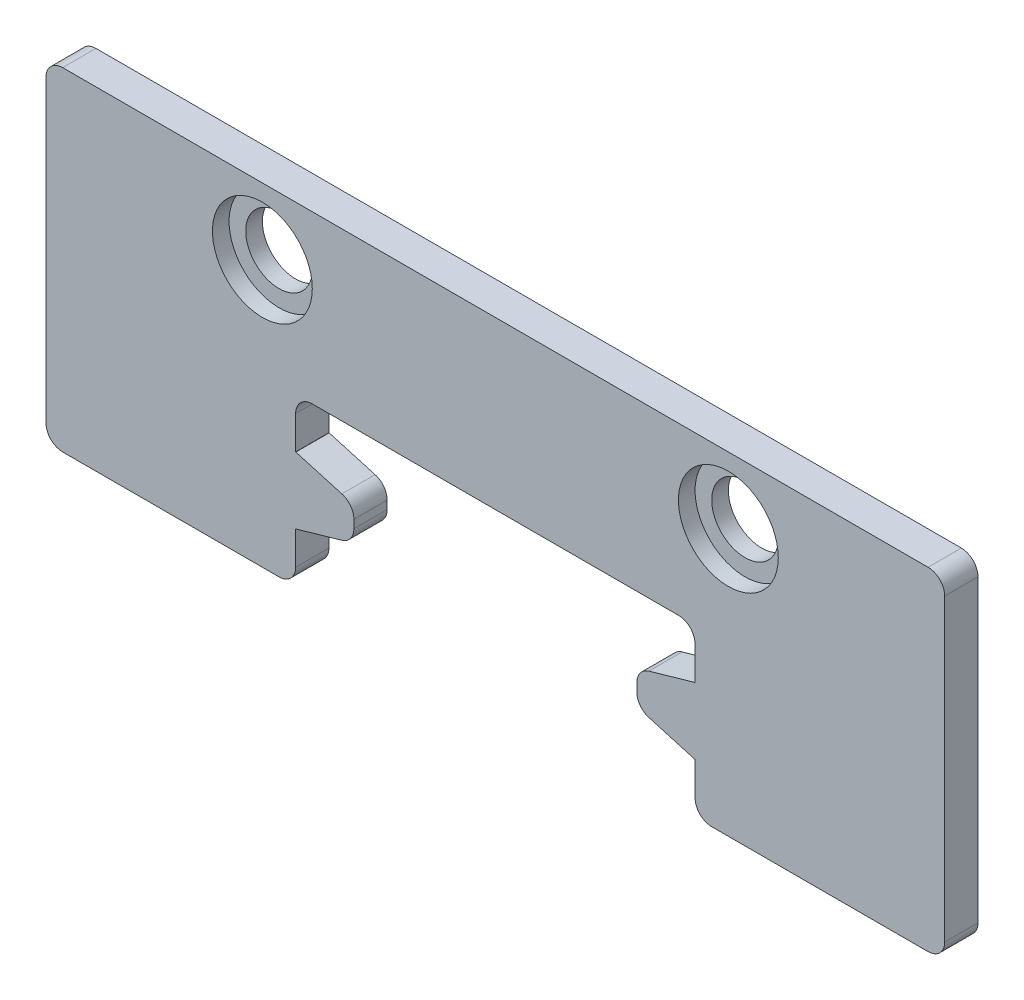
from build123d import *

# Parameters (mm, degrees)
BOSS_EXTRUDE1_DEPTH   = 1
CHAMFER1_SIZE         = 0.5
CHAMFER1_SIZE2        = 1.743707222
CHAMFER1_PART_2_SIZE  = 0.5
CHAMFER1_PART_2_SIZE2 = 1.743707222
FILLET1_R             = 0.5
SKETCH2_R             = 1
CUT_EXTRUDE1_DEPTH    = 1
FILLET2_R             = 0.5
SKETCH3_R             = 1.5
CUT_EXTRUDE2_DEPTH    = 0.5


with BuildPart() as part:
    # Sketch1 → Boss-Extrude1 (new body)
    with BuildSketch(Plane.XY):
        Polygon((-6, -1.5), (-6, 0), (6, 0), (6, -1.5), (4.25, -1.5), (4.25, -3.5), (6, -3.5), (6, -5), (13.5, -5), (13.5, 5), (-13.5, 5), (-13.5, -5), (-6, -5), (-6, -3.5), (-4.25, -3.5), (-4.25, -1.5), align=None)
    extrude(amount=BOSS_EXTRUDE1_DEPTH)

    # Chamfer1
    chamfer1_edges = [part.edges().sort_by_distance(p)[0] for p in [
        (4.25, -3.5, 0.5),
        (4.25, -1.5, 0.5),
    ]]
    chamfer1_side = [part.faces().sort_by_distance(p)[0] for p in [
        (4.25, -2.5, 0.5),
    ]]
    chamfer(chamfer1_edges, length=CHAMFER1_SIZE, length2=CHAMFER1_SIZE2, reference=chamfer1_side[0])

    # Chamfer1 part 2
    chamfer1_part_2_edges = [part.edges().sort_by_distance(p)[0] for p in [
        (-4.25, -1.5, 0.5),
        (-4.25, -3.5, 0.5),
    ]]
    chamfer1_part_2_side = [part.faces().sort_by_distance(p)[0] for p in [
        (-4.25, -2.5, 0.5),
    ]]
    chamfer(chamfer1_part_2_edges, length=CHAMFER1_PART_2_SIZE, length2=CHAMFER1_PART_2_SIZE2, reference=chamfer1_part_2_side[0])

    # Fillet1
    fillet1_edges = [part.edges().sort_by_distance(p)[0] for p in [
        (4.25, -2, 0.5),
        (4.25, -3, 0.5),
        (-4.25, -2, 0.5),
        (-4.25, -3, 0.5),
    ]]
    fillet(fillet1_edges, radius=FILLET1_R)

    # Sketch2 → Cut-Extrude1 (cut)
    with BuildSketch(Plane.XY.offset(1)):
        with Locations((-7, 3)):
            Circle(SKETCH2_R)
        with Locations((7, 3)):
            Circle(SKETCH2_R)
    extrude(amount=-CUT_EXTRUDE1_DEPTH, mode=Mode.SUBTRACT)

    # Fillet2
    fillet2_edges = [part.edges().sort_by_distance(p)[0] for p in [
        (6, -5, 0.5),
        (6, 0, 0.5),
        (-6, 0, 0.5),
        (-6, -5, 0.5),
        (-13.5, -5, 0.5),
        (-13.5, 5, 0.5),
        (13.5, 5, 0.5),
        (13.5, -5, 0.5),
    ]]
    fillet(fillet2_edges, radius=FILLET2_R)

    # Sketch3 → Cut-Extrude2 (cut)
    with BuildSketch(Plane.XY.offset(1)):
        with Locations((-7, 3)):
            Circle(SKETCH3_R)
        with Locations((7, 3)):
            Circle(SKETCH3_R)
    extrude(amount=-CUT_EXTRUDE2_DEPTH, mode=Mode.SUBTRACT)


solid = part.part
